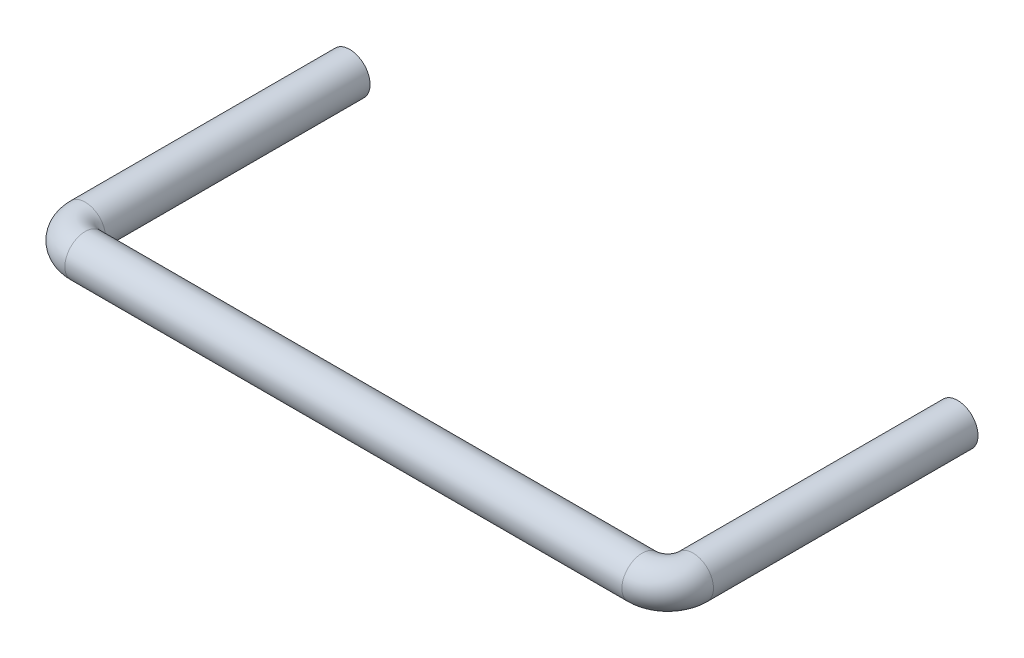
from build123d import *

# Parameters (mm, degrees)
SWEEP1_PROFILE_R = 0.8


with BuildPart() as part:
    # Sweep1: sweep along a path in Sketch1
    with BuildLine(Plane(origin=(0, 0, 0), x_dir=(1, 0, 0), z_dir=(0, 1, 0))) as sweep1_path:
        Line((11.95, 0), (11.95, -10.4))
        ThreePointArc((11.95, -10.4), (11.657106781, -11.107106781), (10.95, -11.4))
        Line((10.95, -11.4), (-10.95, -11.4))
        ThreePointArc((-10.95, -11.4), (-11.657106781, -11.107106781), (-11.95, -10.4))
        Line((-11.95, -10.4), (-11.95, 0))
    # Sweep1 profile (on start of the path) → Sweep1 (sweep)
    with BuildSketch(Plane(origin=(11.95, 0, 0), x_dir=(1, 0, 0), z_dir=(0, 0, 1))):
        Circle(SWEEP1_PROFILE_R)
    sweep(path=sweep1_path.line)


solid = part.part
